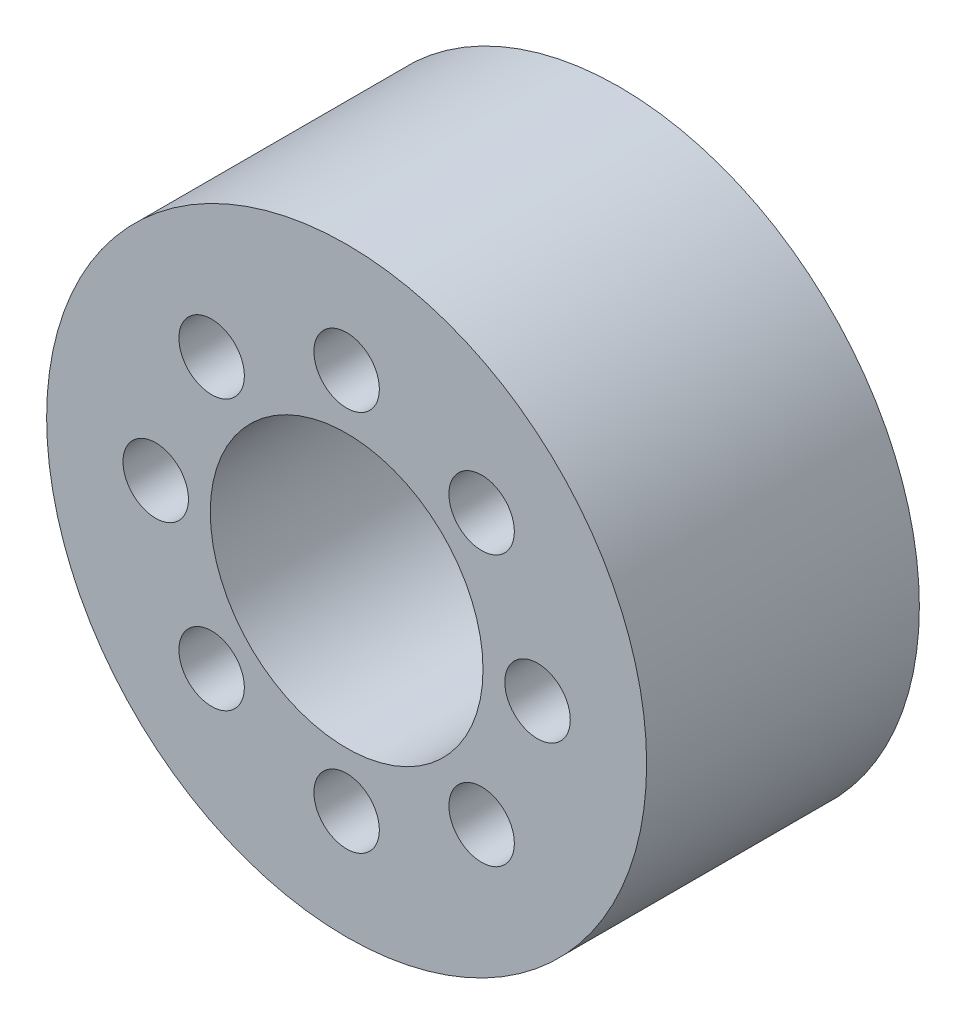
from build123d import *

# Parameters (mm, degrees)
ESQUISSE1_R          = 11
ESQUISSE1_R_2        = 5
BOSS_EXTRU_1_DEPTH   = 10
D_GAGEMENT_M21_D     = 2.4
D_GAGEMENT_M21_DEPTH = 10


with BuildPart() as part:
    # Esquisse1 → Boss.-Extru.1 (new body)
    with BuildSketch(Plane.XY):
        Circle(ESQUISSE1_R)
        Circle(ESQUISSE1_R_2, mode=Mode.SUBTRACT)
    extrude(amount=BOSS_EXTRU_1_DEPTH)

    # Dégagement M21
    with Locations(Plane.XY.offset(10)):
        with Locations((0, 7), (4.949747468, 4.949747468), (7, 0), (4.949747468, -4.949747468), (0, -7), (-4.949747468, -4.949747468), (-7, 0), (-4.949747468, 4.949747468), (0, 0)):
            Hole(D_GAGEMENT_M21_D / 2, depth=D_GAGEMENT_M21_DEPTH)


solid = part.part
